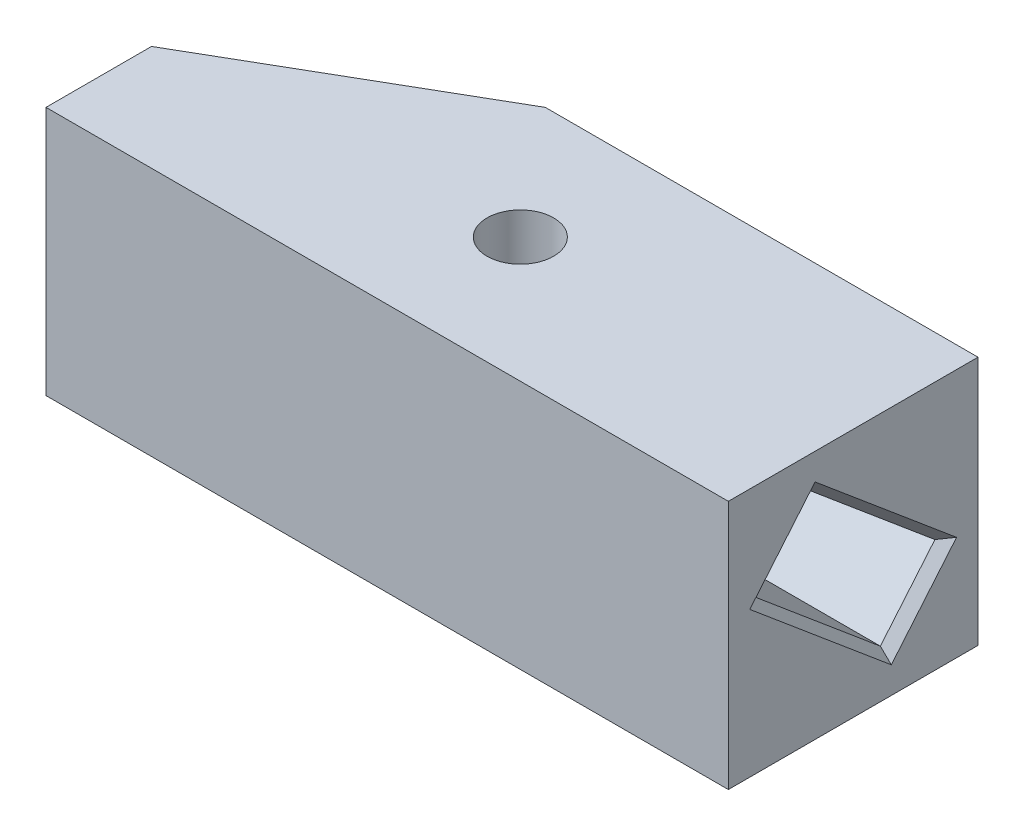
from build123d import *

# Parameters (mm, degrees)
EXTRUDE_1_DEPTH     = 30
SKETCH_2_R          = 4
CUT_EXTRUDE_1_DEPTH = 31
CUT_EXTRUDE_4_DEPTH = 30
SKETCH1_W           = 30
SKETCH1_H           = 30
BOSS_EXTRUDE1_DEPTH = 27
CHAMFER1_SIZE       = 30
CHAMFER1_SIZE2      = 17.320508076
CHAMFER2_SIZE       = 1
CHAMFER2_SIZE2      = 1.191753593


with BuildPart() as part:
    # Эскиз1 → Бобышка-Вытянуть1 (new body)
    with BuildSketch(Plane(origin=(0, 0, 0), x_dir=(1, 0, 0), z_dir=(0, 1, 0))):
        Polygon((-20, -15), (-35, -15), (-35, 15), (-20, 15), (20, 15), (20, -15), align=None)
    extrude(amount=EXTRUDE_1_DEPTH)

    # Эскиз2 → Вырез-Вытянуть1 (cut, through all)
    with BuildSketch(Plane(origin=(0, 30, 0), x_dir=(1, 0, 0), z_dir=(0, 1, 0))):
        with Locations(Location((-20, 0, 0), (0, 0, 270))):  # turned: the seam where the file's is
            Circle(SKETCH_2_R)
    extrude(amount=-CUT_EXTRUDE_1_DEPTH, mode=Mode.SUBTRACT)

    # Эскиз5 → Вырез-Вытянуть4 (cut)
    with BuildSketch(Plane(origin=(20, 0, 0), x_dir=(0, 0, -1), z_dir=(1, 0, 0))):
        Polygon((4.458832066, 4.601018482), (11.015265685, 12.414671802), (-4.458832066, 25.398981518), (-11.015265685, 17.585328198), align=None)
    extrude(amount=-CUT_EXTRUDE_4_DEPTH, mode=Mode.SUBTRACT)

    # Sketch1 → Boss-Extrude1 (add)
    with BuildSketch(Plane.ZY.offset(35)):
        with Locations((0, 15)):
            Rectangle(SKETCH1_W, SKETCH1_H)
    extrude(amount=BOSS_EXTRUDE1_DEPTH)

    # Chamfer1
    chamfer1_edges = [part.edges().sort_by_distance(p)[0] for p in [
        (-62, 15, -15),
    ]]
    chamfer1_side = [part.faces().sort_by_distance(p)[0] for p in [
        (-21, 15, -15),
    ]]
    chamfer(chamfer1_edges, length=CHAMFER1_SIZE, length2=CHAMFER1_SIZE2, reference=chamfer1_side[0])

    # Chamfer2
    chamfer2_edges = [part.edges().sort_by_distance(p)[0] for p in [
        (20, 18.90682666, -3.278216809),
        (20, 21.492154858, 7.737048876),
        (20, 11.09317334, 3.278216809),
        (20, 8.507845142, -7.737048876),
    ]]
    chamfer2_side = [part.faces().sort_by_distance(p)[0] for p in [
        (20, 15, -14.575735931),
    ]]
    chamfer(chamfer2_edges, length=CHAMFER2_SIZE, length2=CHAMFER2_SIZE2, reference=chamfer2_side[0])


solid = part.part
